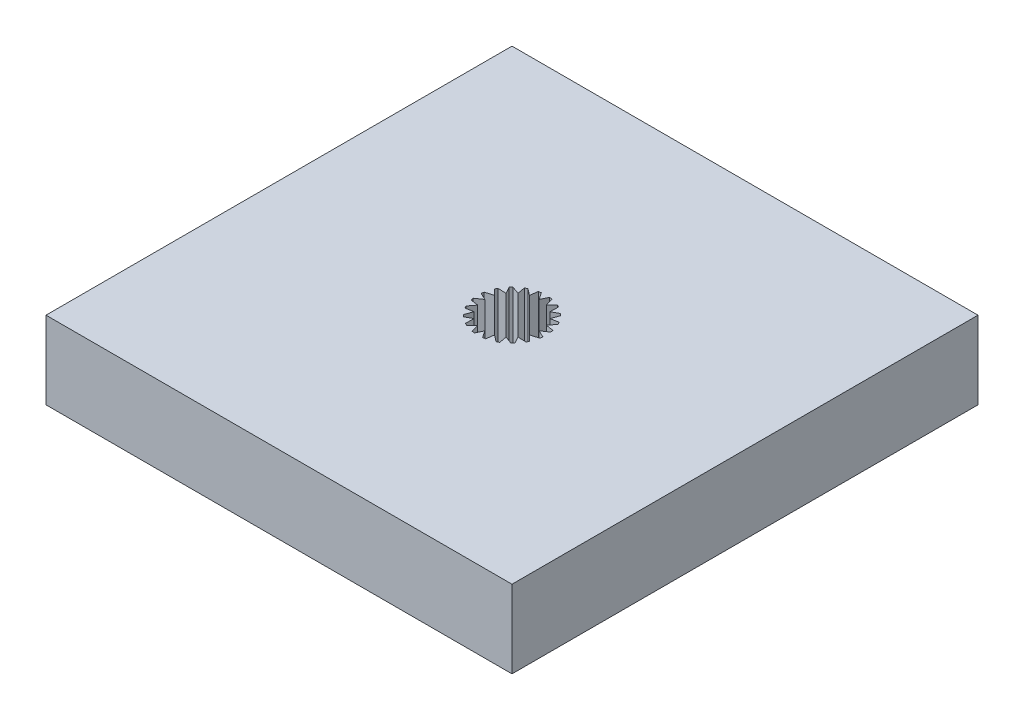
from build123d import *

# Parameters (mm, degrees)
SKETCH4_W           = 38.1
SKETCH4_H           = 38.1
BOSS_EXTRUDE2_DEPTH = 6.35


with BuildPart() as part:
    # Sketch4 → Boss-Extrude2 (new body)
    with BuildSketch(Plane(origin=(0, 0, 0), x_dir=(1, 0, 0), z_dir=(0, 1, 0))):
        Rectangle(SKETCH4_W, SKETCH4_H)
        Polygon((-1.949674864, 2.027811191), (-1.306816157, 1.798678132), (-1.420768443, 2.4278936), (-1.227622865, 2.531045714), (-0.687033912, 2.114472959), (-0.600970703, 2.748105623), (-0.385402586, 2.786523847), (0, 2.223288441), (0.277654237, 2.799313921), (0.494543583, 2.769237611), (0.687033912, 2.114472959), (1.129100445, 2.576505868), (1.326080381, 2.480879103), (1.306816157, 1.798678132), (1.870022435, 2.101491469), (2.027811191, 1.949674864), (1.798678132, 1.306816157), (2.4278936, 1.420768443), (2.531045714, 1.227622865), (2.114472959, 0.687033912), (2.748105623, 0.600970703), (2.786523847, 0.385402586), (2.223288441, 0), (2.799313921, -0.277654237), (2.769237611, -0.494543583), (2.114472959, -0.687033912), (2.576505868, -1.129100445), (2.480879103, -1.326080381), (1.798678132, -1.306816157), (2.101491469, -1.870022435), (1.949674864, -2.027811191), (1.316448269, -1.80211129), (1.420768443, -2.4278936), (1.227622865, -2.531045714), (0.687033912, -2.114472959), (0.600970703, -2.748105623), (0.385402586, -2.786523847), (0, -2.223288441), (-0.277654237, -2.799313921), (-0.494543583, -2.769237611), (-0.687033912, -2.114472959), (-1.129100445, -2.576505868), (-1.326080381, -2.480879103), (-1.306816157, -1.798678132), (-1.870022435, -2.101491469), (-2.027811191, -1.949674864), (-1.798678132, -1.306816157), (-2.4278936, -1.420768443), (-2.531045714, -1.227622865), (-2.114472959, -0.687033912), (-2.748105623, -0.600970703), (-2.786523847, -0.385402586), (-2.223288441, 0), (-2.799313921, 0.277654237), (-2.769237611, 0.494543583), (-2.114472959, 0.687033912), (-2.576505868, 1.129100445), (-2.480879103, 1.326080381), (-1.798678132, 1.306816157), (-2.101491469, 1.870022435), align=None, mode=Mode.SUBTRACT)
    extrude(amount=BOSS_EXTRUDE2_DEPTH)


solid = part.part
